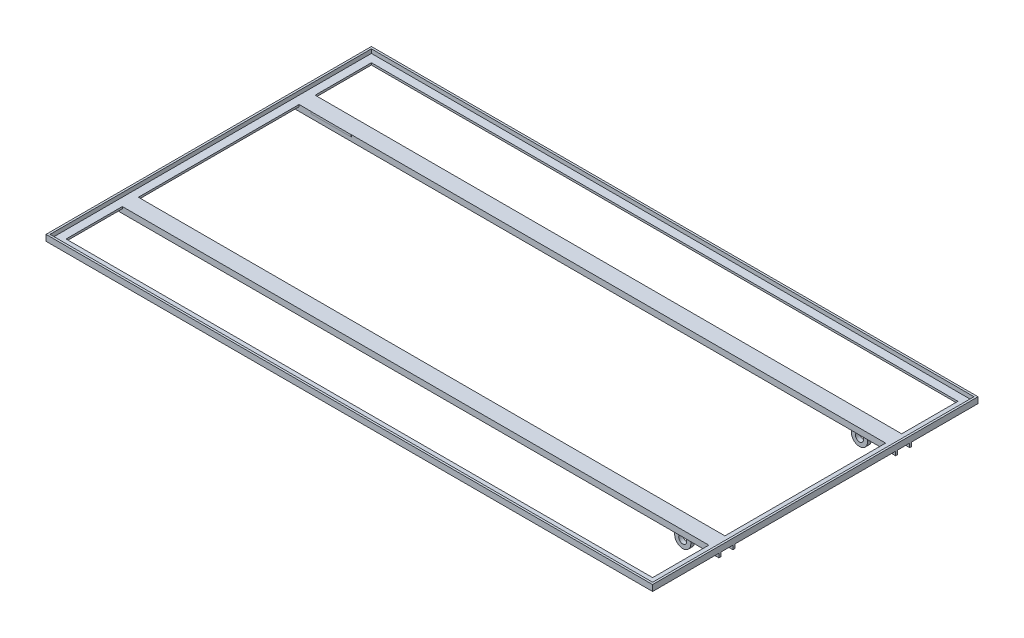
from build123d import *

# Parameters (mm, degrees)
SKETCH2_W                 = 1510
SKETCH2_H                 = 810
SKETCH2_W_2               = 1500
SKETCH2_H_2               = 800
BOSS_EXTRUDE1_DEPTH       = 10
SKETCH3_W                 = 1510
SKETCH3_H                 = 810
SKETCH3_W_2               = 1460
SKETCH3_H_2               = 140
SKETCH3_W_3               = 30
SKETCH3_H_3               = 400
SKETCH3_W_4               = 1200
BOSS_EXTRUDE2_DEPTH       = 5
SKETCH5_W                 = 1510
SKETCH5_H                 = 5
BOSS_EXTRUDE3_DEPTH       = 10
LPATTERN1_COUNT           = 2
LPATTERN1_PITCH           = 35
LPATTERN2_COUNT           = 2
LPATTERN2_PITCH           = 440
LPATTERN2_COPY_1_SKETCH_W = 1510
LPATTERN2_COPY_1_SKETCH_H = 5
LPATTERN2_COPY_1_DEPTH    = 10
SKETCH6_R                 = 10
BOSS_EXTRUDE4_DEPTH       = 5
LPATTERN3_COUNT           = 2
LPATTERN3_PITCH           = 440
SKETCH7_W                 = 100
SKETCH7_H                 = 399.729040111
SKETCH7_H_2               = 400
CUT_EXTRUDE5_DEPTH        = 10


with BuildPart() as part:
    # Sketch2 → Boss-Extrude1 (new body)
    with BuildSketch(Plane(origin=(0, 0, 0), x_dir=(1, 0, 0), z_dir=(0, 1, 0))):
        Rectangle(SKETCH2_W, SKETCH2_H)
        Rectangle(SKETCH2_W_2, SKETCH2_H_2, mode=Mode.SUBTRACT)
    extrude(amount=BOSS_EXTRUDE1_DEPTH)

    # Sketch3 → Boss-Extrude2 (add)
    with BuildSketch(Plane(origin=(0, 0, 0), x_dir=(1, 0, 0), z_dir=(0, 1, 0))):
        Rectangle(SKETCH3_W, SKETCH3_H)
        with Locations((0, -310)):
            Rectangle(SKETCH3_W_2, SKETCH3_H_2, mode=Mode.SUBTRACT)
        with Locations((0, 310)):
            Rectangle(SKETCH3_W_2, SKETCH3_H_2, mode=Mode.SUBTRACT)
        with Locations((-715, 0)):
            Rectangle(SKETCH3_W_3, SKETCH3_H_3, mode=Mode.SUBTRACT)
        with Locations((715, 0)):
            Rectangle(SKETCH3_W_3, SKETCH3_H_3, mode=Mode.SUBTRACT)
        Rectangle(SKETCH3_W_4, SKETCH3_H_3, mode=Mode.SUBTRACT)
    extrude(amount=-BOSS_EXTRUDE2_DEPTH)

    # Sketch5 → Boss-Extrude3 (add)
    with BuildSketch(Plane.XZ.offset(5)):
        with Locations((0, 237.5)):
            Rectangle(SKETCH5_W, SKETCH5_H)
    boss_extrude3 = extrude(amount=BOSS_EXTRUDE3_DEPTH)

    # LPattern1: Boss-Extrude3 ×2
    with Locations(*[(0, 0, -i * LPATTERN1_PITCH) for i in range(1, LPATTERN1_COUNT)]):
        add(boss_extrude3)

    # LPattern2: Boss-Extrude3 ×2
    with Locations(*[(0, 0, -i * LPATTERN2_PITCH) for i in range(1, LPATTERN2_COUNT)]):
        add(boss_extrude3)

    # LPattern2 copy 1 sketch → LPattern2 copy 1 (add)
    with BuildSketch(Plane(origin=(0, -5, -475), x_dir=(1, 0, 0), z_dir=(0, -1, 0))):
        with Locations((0, 237.5)):
            Rectangle(LPATTERN2_COPY_1_SKETCH_W, LPATTERN2_COPY_1_SKETCH_H)
    extrude(amount=LPATTERN2_COPY_1_DEPTH)

    # Sketch6 → Boss-Extrude4 (add, symmetric)
    with BuildSketch(Plane.XY.offset(220)):
        with BuildLine():
            Line((630, -5), (630, -35))
            ThreePointArc((630, -35), (650, -55), (670, -35))
            Line((670, -35), (670, -5))
            Line((670, -5), (630, -5))
        make_face()
        with Locations((650, -35)):
            Circle(SKETCH6_R, mode=Mode.SUBTRACT)
    boss_extrude4 = extrude(amount=BOSS_EXTRUDE4_DEPTH, both=True)

    # LPattern3: Boss-Extrude4 ×2
    with Locations(*[(0, 0, -i * LPATTERN3_PITCH) for i in range(1, LPATTERN3_COUNT)]):
        add(boss_extrude4)

    # Sketch7 → Cut-Extrude5 (cut)
    with BuildSketch(Plane.XZ.offset(5)):
        with Locations((-650, 0.135479944)):
            Rectangle(SKETCH7_W, SKETCH7_H)
        with Locations((650, 0)):
            Rectangle(SKETCH7_W, SKETCH7_H_2)
    extrude(amount=-CUT_EXTRUDE5_DEPTH, mode=Mode.SUBTRACT)


solid = part.part
